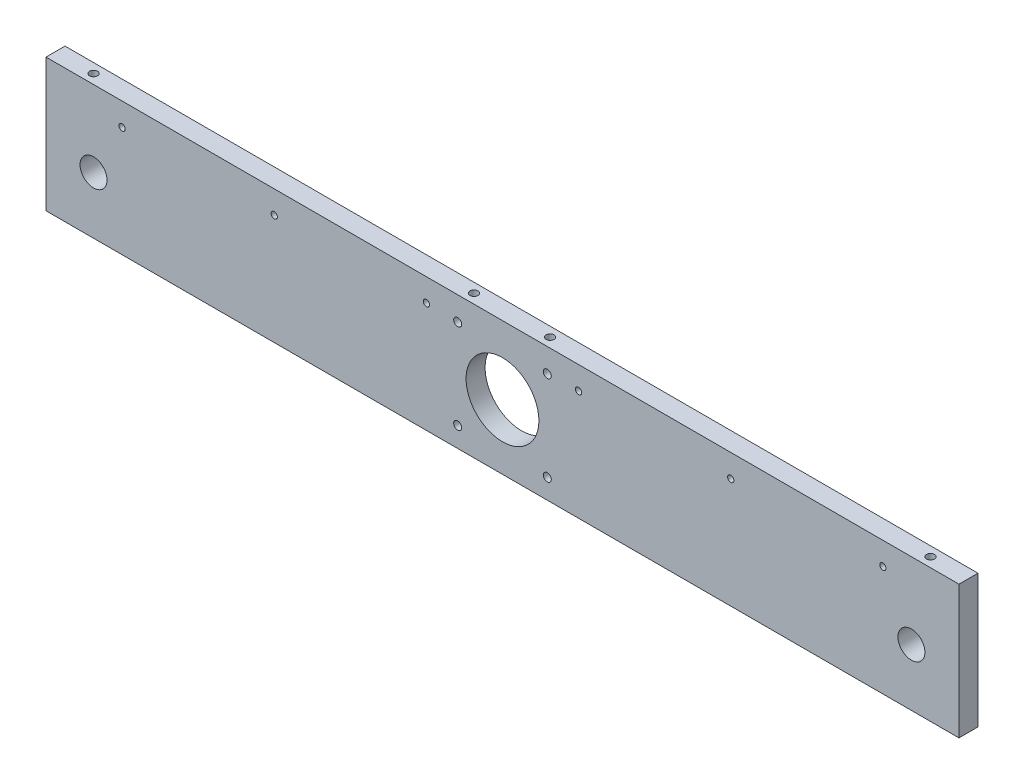
from build123d import *

# Parameters (mm, degrees)
SKETCH1_W                  = 480
SKETCH1_H                  = 70
SKETCH1_R                  = 19.15
SKETCH1_R_2                = 2.1
SKETCH1_R_3                = 7.1
BOSS_EXTRUDE1_DEPTH        = 10
M5_TAPPED_HOLE1_D          = 4.2
M5_TAPPED_HOLE1_DEPTH      = 12.4
M5_TAPPED_HOLE1_TIP        = 1.2618073
M5_TAPPED_HOLE2_D          = 4.2
M5_TAPPED_HOLE2_DEPTH      = 12.4
M5_TAPPED_HOLE2_TIP        = 1.2618073
F_3_3_3_3_DIAMETER_HOLE1_D = 3.3


with BuildPart() as part:
    # Sketch1 → Boss-Extrude1 (new body)
    with BuildSketch(Plane.XY):
        Rectangle(SKETCH1_W, SKETCH1_H)
        with Locations((0, -1)):
            Circle(SKETCH1_R, mode=Mode.SUBTRACT)
        with Locations((-23.55, -24.55)):
            Circle(SKETCH1_R_2, mode=Mode.SUBTRACT)
        with Locations((23.55, -24.55)):
            Circle(SKETCH1_R_2, mode=Mode.SUBTRACT)
        with Locations((23.55, 22.55)):
            Circle(SKETCH1_R_2, mode=Mode.SUBTRACT)
        with Locations((-23.55, 22.55)):
            Circle(SKETCH1_R_2, mode=Mode.SUBTRACT)
        with Locations((-215, -5)):
            Circle(SKETCH1_R_3, mode=Mode.SUBTRACT)
        with Locations((215, -5)):
            Circle(SKETCH1_R_3, mode=Mode.SUBTRACT)
    extrude(amount=BOSS_EXTRUDE1_DEPTH)

    # M5 Tapped Hole1
    with Locations(Plane(origin=(0, 35, 0), x_dir=(1, 0, 0), z_dir=(0, 1, 0))):
        with Locations((220, -5), (-220, -5), (-20, -5), (20, -5)):
            Hole(M5_TAPPED_HOLE1_D / 2, depth=M5_TAPPED_HOLE1_DEPTH)
            with Locations((0, 0, -(M5_TAPPED_HOLE1_DEPTH + M5_TAPPED_HOLE1_TIP / 2))):  # 118° drill point
                Cone(0, M5_TAPPED_HOLE1_D / 2, M5_TAPPED_HOLE1_TIP, mode=Mode.SUBTRACT)

    # M5 Tapped Hole2
    with Locations(Plane(origin=(0, -35, 0), x_dir=(-1, 0, 0), z_dir=(0, -1, 0))):
        with Locations((-220, -5), (220, -5)):
            Hole(M5_TAPPED_HOLE2_D / 2, depth=M5_TAPPED_HOLE2_DEPTH)
            with Locations((0, 0, -(M5_TAPPED_HOLE2_DEPTH + M5_TAPPED_HOLE2_TIP / 2))):  # 118° drill point
                Cone(0, M5_TAPPED_HOLE2_D / 2, M5_TAPPED_HOLE2_TIP, mode=Mode.SUBTRACT)

    # Ø3.3 (3.3) Diameter Hole1 (through all)
    with Locations(Plane.XY.offset(10)):
        with Locations((-200, 23), (-120, 23), (-40, 23), (40, 23), (120, 23), (200, 23)):
            Hole(F_3_3_3_3_DIAMETER_HOLE1_D / 2)


solid = part.part
